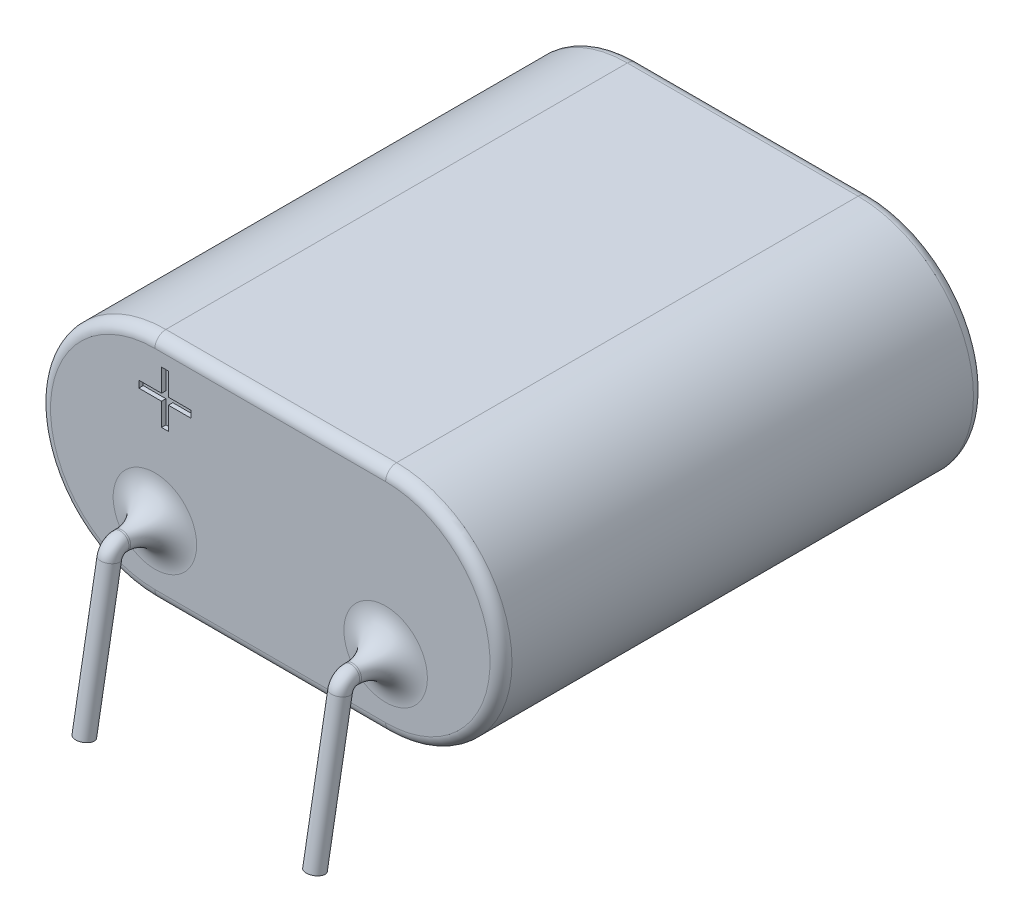
from build123d import *

# Parameters (mm, degrees)
BOSS_EXTRUDE1_DEPTH = 22
SKETCH2_R           = 0.4
FILLET1_R           = 1.5
FILLET2_R           = 0.5
CUT_EXTRUDE1_DEPTH  = 0.2


with BuildPart() as part:
    # Sketch1 → Boss-Extrude1 (new body)
    with BuildSketch(Plane.XY):
        with BuildLine():
            Line((0, 5.25), (10.5, 5.25))
            ThreePointArc((10.5, 5.25), (15.75, 0), (10.5, -5.25))
            Line((10.5, -5.25), (0, -5.25))
            ThreePointArc((0, -5.25), (-5.25, 0), (0, 5.25))
        make_face()
    extrude(amount=-BOSS_EXTRUDE1_DEPTH)

    # Sweep1: sweep along a path in Sketch3
    with BuildLine(Plane.YZ) as sweep1_path:
        Line((-2.05, 0), (-2.05, 1.580450184))
        ThreePointArc((-2.05, 1.580450184), (-2.166977778, 1.901843989), (-2.463175911, 2.072854061))
        Line((-2.463175911, 2.072854061), (-8.943654271, 3.215537244))
    # Sketch2 → Sweep1 (sweep)
    with BuildSketch(Plane.XY):
        with Locations((0, -2.05)):
            Circle(SKETCH2_R)
        with Locations((10.5, -2.05)):
            Circle(SKETCH2_R)
    sweep(path=sweep1_path.line)

    # Fillet1
    fillet1_edges = [part.edges().sort_by_distance(p)[0] for p in [
        (10.1, -2.05, 0),
        (-0.4, -2.05, 0),
    ]]
    fillet(fillet1_edges, radius=FILLET1_R)

    # Fillet2
    fillet2_edges = [part.edges().sort_by_distance(p)[0] for p in [
        (5.25, -5.25, -22),
        (15.75, 0, -22),
        (5.25, 5.25, -22),
        (-5.25, 0, -22),
        (5.25, 5.25, 0),
        (15.75, 0, 0),
        (5.25, -5.25, 0),
        (-5.25, 0, 0),
    ]]
    fillet(fillet2_edges, radius=FILLET2_R)

    # Sketch4 → Cut-Extrude1 (cut)
    with BuildSketch(Plane.XY):
        Polygon((0.301282051, 3.134615385), (0.301282051, 4.166666667), (0.615384615, 4.166666667), (0.615384615, 3.134615385), (1.647435897, 3.134615385), (1.647435897, 2.820512821), (0.615384615, 2.820512821), (0.615384615, 1.788461538), (0.301282051, 1.788461538), (0.301282051, 2.820512821), (-0.730769231, 2.820512821), (-0.730769231, 3.134615385), align=None)
    extrude(amount=-CUT_EXTRUDE1_DEPTH, mode=Mode.SUBTRACT)


solid = part.part
